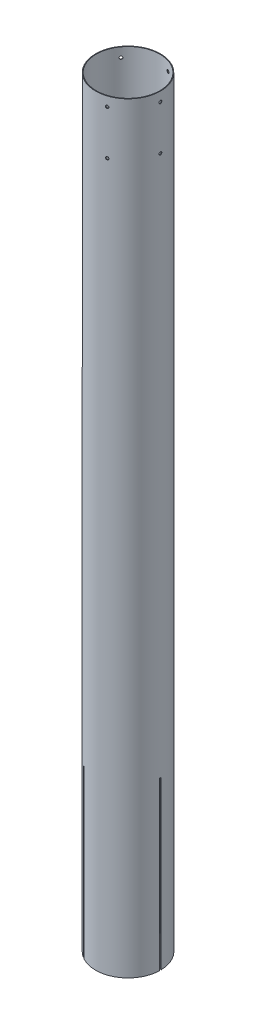
from build123d import *

# Parameters (mm, degrees)
SKETCH1_R                       = 58.299985
BOSS_EXTRUDE1_DEPTH             = 1370.16998
SKETCH2_R                       = 57.15
CUT_EXTRUDE1_DEPTH              = 1370.16998
SKETCH3_W                       = 3
SKETCH3_H                       = 300
CUT_EXTRUDE2_DEPTH              = 10
CIRPATTERN1_COUNT               = 3
F_6_0_204_DIAMETER_HOLE1_REACH  = 1378.358
F_6_0_204_DIAMETER_HOLE1_BORE_R = 2.5908
CIRPATTERN2_COUNT               = 5


with BuildPart() as part:
    # Sketch1 → Boss-Extrude1 (new body)
    with BuildSketch(Plane(origin=(0, 0, 0), x_dir=(1, 0, 0), z_dir=(0, 1, 0))):
        with Locations(Location((0, 0, 0), (0, 0, 270))):
            Circle(SKETCH1_R)
    extrude(amount=BOSS_EXTRUDE1_DEPTH)

    # Sketch2 → Cut-Extrude1 (cut)
    with BuildSketch(Plane(origin=(0, 0, 0), x_dir=(1, 0, 0), z_dir=(0, 1, 0))):
        with Locations(Location((0, 0, 0), (0, 0, 270))):
            Circle(SKETCH2_R)
    extrude(amount=CUT_EXTRUDE1_DEPTH, mode=Mode.SUBTRACT)

    # Sketch3 → Cut-Extrude2 (cut)
    with BuildSketch(Plane(origin=(58.299985, 0, 0), x_dir=(0, 0, -1), z_dir=(1, 0, 0))):
        with Locations((0, 150)):
            Rectangle(SKETCH3_W, SKETCH3_H)
    cut_extrude2 = extrude(amount=-CUT_EXTRUDE2_DEPTH, mode=Mode.SUBTRACT)

    # CirPattern1: Cut-Extrude2 ×3 about axis
    cirpattern1_axis = Axis((0, 0, 0), (0, 1, 0))
    for i in range(1, CIRPATTERN1_COUNT):
        add(cut_extrude2.rotate(cirpattern1_axis, i * 360 / CIRPATTERN1_COUNT), mode=Mode.SUBTRACT)

    # #6 (0.204) Diameter Hole1 bore → #6 (0.204) Diameter Hole1 (cut, up to next)
    with BuildSketch(Plane(origin=(58.299985, 0, 0), x_dir=(0, 0, -1), z_dir=(1, 0, 0)), mode=Mode.PRIVATE) as f_6_0_204_diameter_hole1_sk1:
        with Locations((0, 1353.17738)):
            Circle(F_6_0_204_DIAMETER_HOLE1_BORE_R)
    f_6_0_204_diameter_hole1_tool1 = extrude(f_6_0_204_diameter_hole1_sk1.sketch, amount=-F_6_0_204_DIAMETER_HOLE1_REACH, mode=Mode.PRIVATE) & part.part
    # #6 (0.204) Diameter Hole1 bore → #6 (0.204) Diameter Hole1 (cut, up to next)
    with BuildSketch(Plane(origin=(58.299985, 0, 0), x_dir=(0, 0, -1), z_dir=(1, 0, 0)), mode=Mode.PRIVATE) as f_6_0_204_diameter_hole1_sk2:
        with Locations((0, 1273.16738)):
            Circle(F_6_0_204_DIAMETER_HOLE1_BORE_R)
    f_6_0_204_diameter_hole1_tool2 = extrude(f_6_0_204_diameter_hole1_sk2.sketch, amount=-F_6_0_204_DIAMETER_HOLE1_REACH, mode=Mode.PRIVATE) & part.part
    f_6_0_204_diameter_hole1_1 = f_6_0_204_diameter_hole1_tool1.solids().sort_by_distance((58.299985, 1353.17738, 0))[0]
    add(f_6_0_204_diameter_hole1_1, mode=Mode.SUBTRACT)
    f_6_0_204_diameter_hole1_2 = f_6_0_204_diameter_hole1_tool2.solids().sort_by_distance((58.299985, 1273.16738, 0))[0]
    add(f_6_0_204_diameter_hole1_2, mode=Mode.SUBTRACT)
    f_6_0_204_diameter_hole1 = f_6_0_204_diameter_hole1_1 + f_6_0_204_diameter_hole1_2  # #6 (0.204) Diameter Hole1 as one shape, for the pattern or mirror that repeats it

    # CirPattern2: #6 (0.204) Diameter Hole1 ×5 about axis
    cirpattern2_axis = Axis((0, 0, 0), (0, -1, 0))
    for i in range(1, CIRPATTERN2_COUNT):
        add(f_6_0_204_diameter_hole1.rotate(cirpattern2_axis, i * 360 / CIRPATTERN2_COUNT), mode=Mode.SUBTRACT)


solid = part.part
